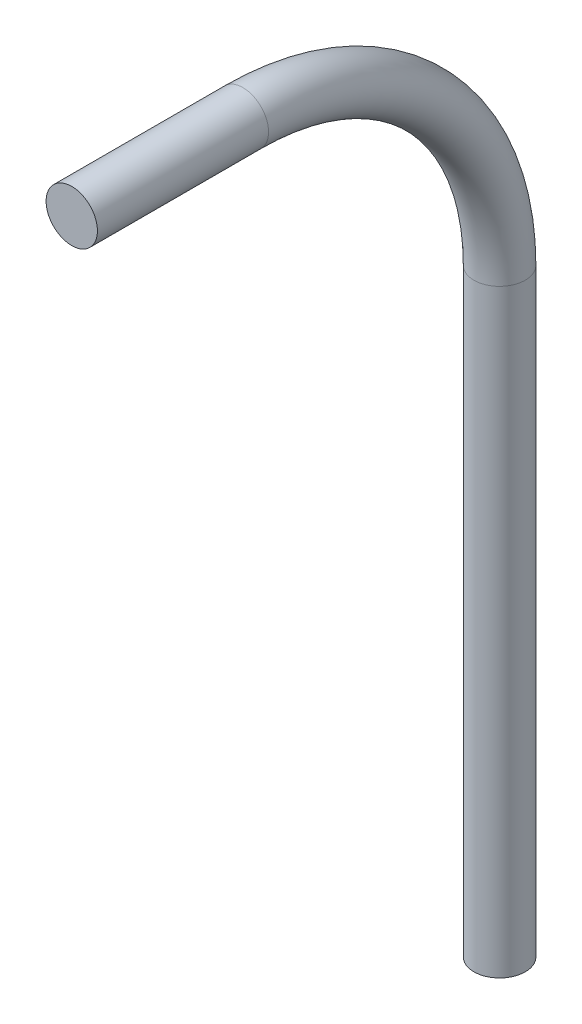
from build123d import *

# Parameters (mm, degrees)
SKETCH1_R = 3


with BuildPart() as part:
    # Sweep1: sweep along a path in Sketch3
    with BuildLine(Plane(origin=(0, 0, 0), x_dir=(0, 0, -1), z_dir=(1, 0, 0))) as sweep1_path:
        Line((0, 0), (20, 0))
        ThreePointArc((20, 0), (41.213203436, -8.786796564), (50, -30))
        Line((50, -30), (50, -100))
    # Sketch1 → Sweep1 (sweep)
    with BuildSketch(Plane.XY):
        Circle(SKETCH1_R)
    sweep(path=sweep1_path.line)


solid = part.part
